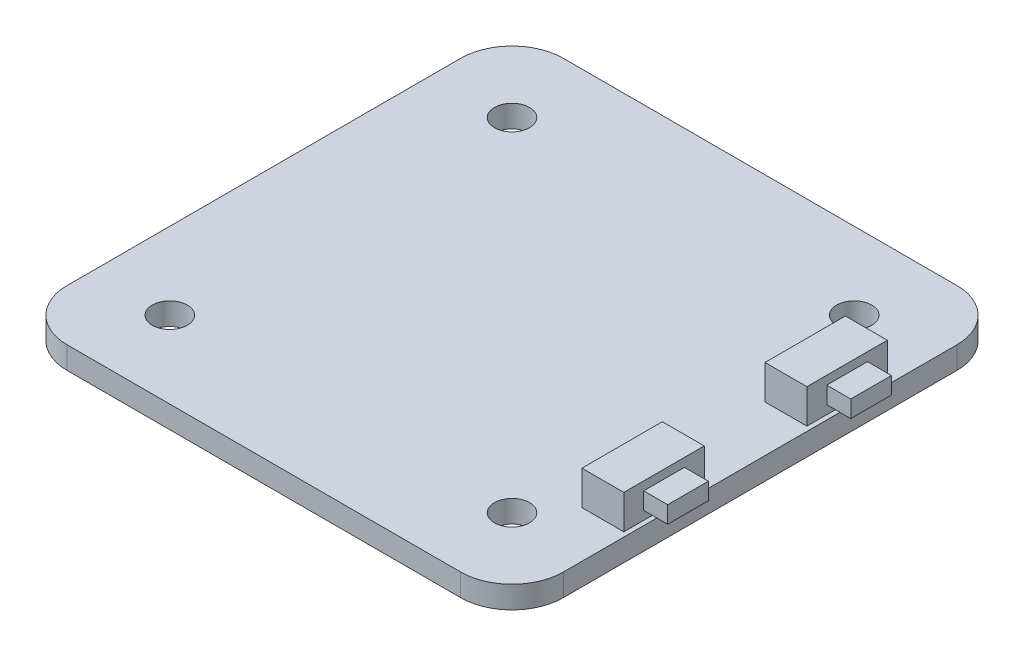
from build123d import *

# Parameters (mm, degrees)
SKETCH1_R           = 1.025
BOSS_EXTRUDE1_DEPTH = 1.3
SKETCH2_W           = 2.45
SKETCH2_H           = 4.7
BOSS_EXTRUDE2_DEPTH = 2
SKETCH3_W           = 2.378127828
SKETCH3_H           = 0.99144163
BOSS_EXTRUDE3_DEPTH = 1.4


with BuildPart() as part:
    # Sketch1 → Boss-Extrude1 (new body)
    with BuildSketch(Plane(origin=(0, 0, 0), x_dir=(1, 0, 0), z_dir=(0, 1, 0))):
        with BuildLine():
            Line((3, 0), (26, 0))
            ThreePointArc((26, 0), (28.121320344, 0.878679656), (29, 3))
            Line((29, 3), (29, 26))
            ThreePointArc((29, 26), (28.121320344, 28.121320344), (26, 29))
            Line((26, 29), (3, 29))
            ThreePointArc((3, 29), (0.878679656, 28.121320344), (0, 26))
            Line((0, 26), (0, 3))
            ThreePointArc((0, 3), (0.878679656, 0.878679656), (3, 0))
        make_face()
        with Locations((4.5, 24.5)):
            Circle(SKETCH1_R, mode=Mode.SUBTRACT)
        with Locations((24.5, 24.5)):
            Circle(SKETCH1_R, mode=Mode.SUBTRACT)
        with Locations((24.5, 4.5)):
            Circle(SKETCH1_R, mode=Mode.SUBTRACT)
        with Locations((4.5, 4.5)):
            Circle(SKETCH1_R, mode=Mode.SUBTRACT)
    extrude(amount=BOSS_EXTRUDE1_DEPTH)

    # Sketch2 → Boss-Extrude2 (add)
    with BuildSketch(Plane(origin=(0, 1.3, 0), x_dir=(1, 0, 0), z_dir=(0, 1, 0))):
        with Locations((27.511966954, 19.85)):
            Rectangle(SKETCH2_W, SKETCH2_H)
        with Locations((27.511966954, 9.15)):
            Rectangle(SKETCH2_W, SKETCH2_H)
    extrude(amount=BOSS_EXTRUDE2_DEPTH)

    # Sketch3 → Boss-Extrude3 (add)
    with BuildSketch(Plane(origin=(28.736966954, 0, 0), x_dir=(0, 0, -1), z_dir=(1, 0, 0))):
        with Locations((9.15, 2.3)):
            Rectangle(SKETCH3_W, SKETCH3_H)
        with Locations((19.85, 2.3)):
            Rectangle(SKETCH3_W, SKETCH3_H)
    extrude(amount=BOSS_EXTRUDE3_DEPTH)


solid = part.part
